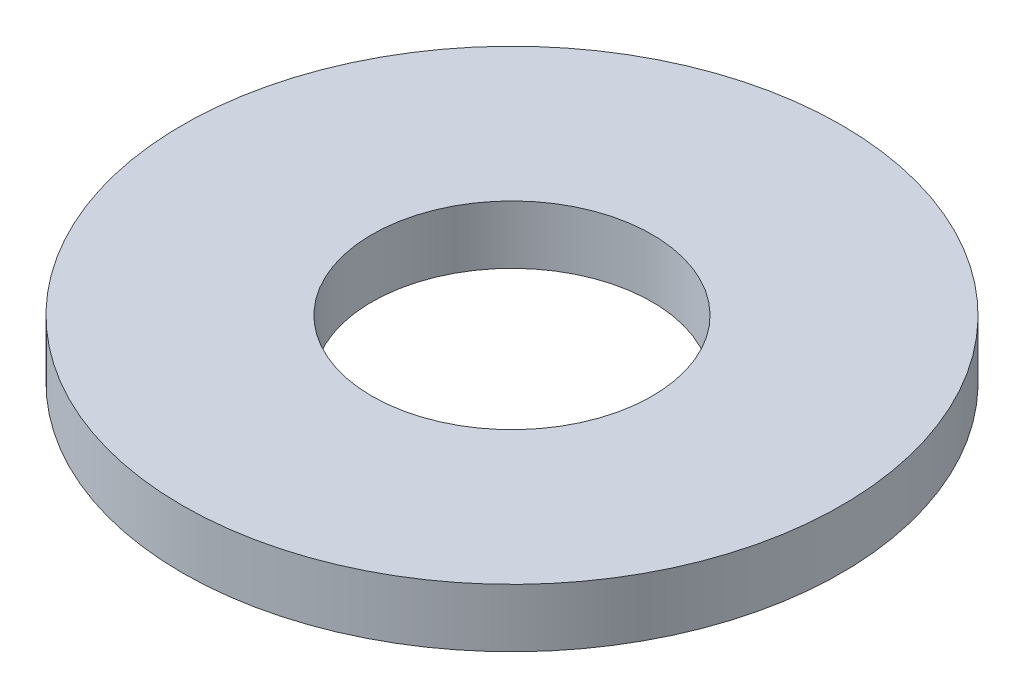
from build123d import *

# Parameters (mm, degrees)
SKETCH1_R           = 9.3218
SKETCH1_R_2         = 3.9624
BOSS_EXTRUDE1_DEPTH = 1.651


with BuildPart() as part:
    # Sketch1 → Boss-Extrude1 (new body)
    with BuildSketch(Plane(origin=(0, 0, 0), x_dir=(1, 0, 0), z_dir=(0, 1, 0))):
        Circle(SKETCH1_R)
        Circle(SKETCH1_R_2, mode=Mode.SUBTRACT)
    extrude(amount=BOSS_EXTRUDE1_DEPTH)


solid = part.part
